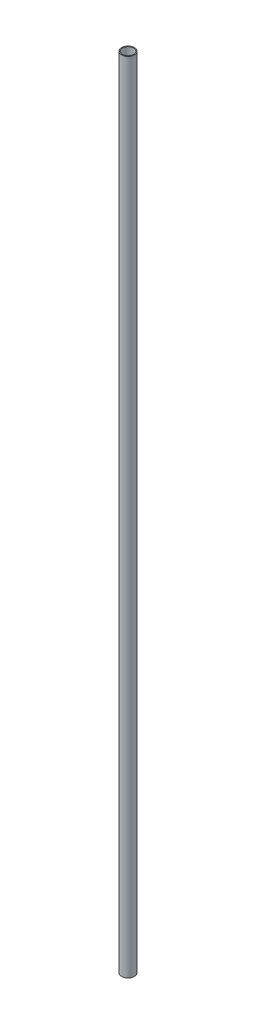
from build123d import *

# Parameters (mm, degrees)
SKETCH1_R           = 4
SKETCH1_R_2         = 3.5
BOSS_EXTRUDE1_DEPTH = 500


with BuildPart() as part:
    # Sketch1 → Boss-Extrude1 (new body)
    with BuildSketch(Plane(origin=(0, 0, 0), x_dir=(1, 0, 0), z_dir=(0, 1, 0))):
        Circle(SKETCH1_R)
        Circle(SKETCH1_R_2, mode=Mode.SUBTRACT)
    extrude(amount=BOSS_EXTRUDE1_DEPTH)


solid = part.part
